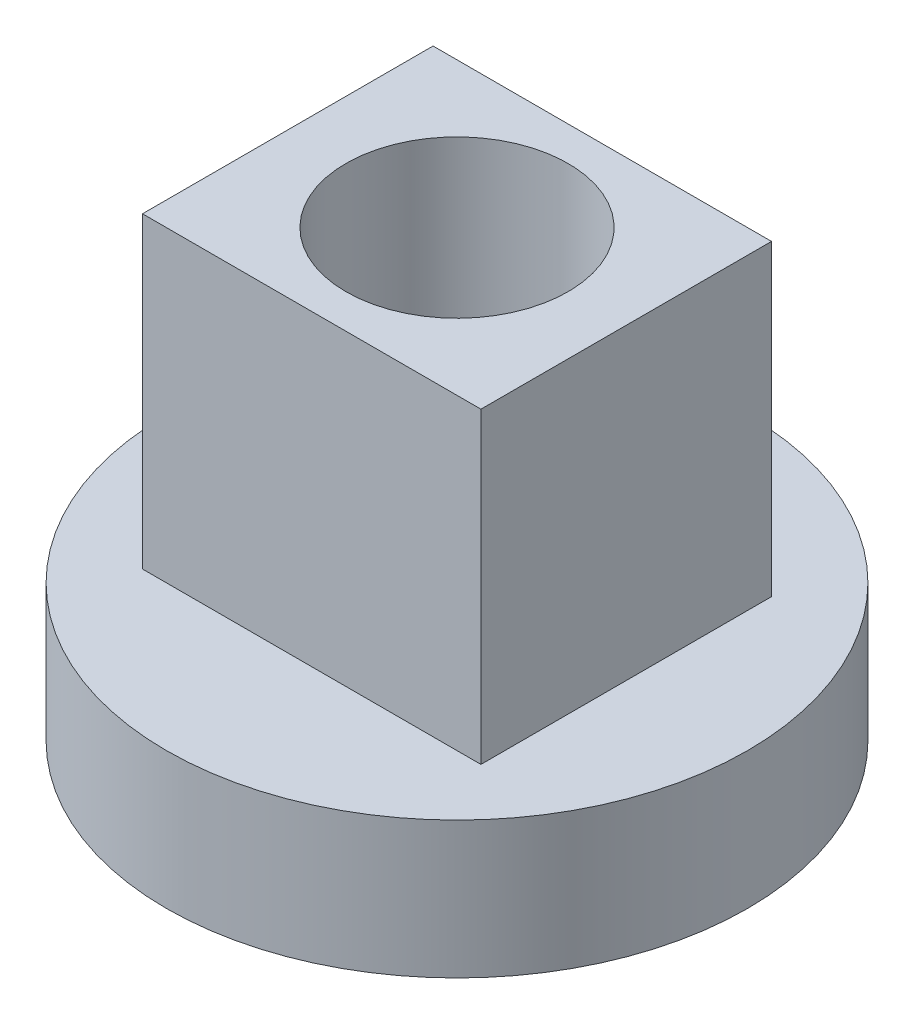
from build123d import *

# Parameters (mm, degrees)
SKETCH1_R           = 4.318
BOSS_EXTRUDE1_DEPTH = 2.032
SKETCH2_W           = 5.0292
SKETCH2_H           = 4.318
BOSS_EXTRUDE2_DEPTH = 4.572
SKETCH3_R           = 1.651
CUT_EXTRUDE1_DEPTH  = 7.604


with BuildPart() as part:
    # Sketch1 → Boss-Extrude1 (new body)
    with BuildSketch(Plane(origin=(0, 0, 0), x_dir=(1, 0, 0), z_dir=(0, 1, 0))):
        Circle(SKETCH1_R)
    extrude(amount=BOSS_EXTRUDE1_DEPTH)

    # Sketch2 → Boss-Extrude2 (add)
    with BuildSketch(Plane(origin=(0, 2.032, 0), x_dir=(1, 0, 0), z_dir=(0, 1, 0))):
        Rectangle(SKETCH2_W, SKETCH2_H)
    extrude(amount=BOSS_EXTRUDE2_DEPTH)

    # Sketch3 → Cut-Extrude1 (cut, through all)
    with BuildSketch(Plane(origin=(0, 6.604, 0), x_dir=(1, 0, 0), z_dir=(0, 1, 0))):
        Circle(SKETCH3_R)
    extrude(amount=-CUT_EXTRUDE1_DEPTH, mode=Mode.SUBTRACT)


solid = part.part
